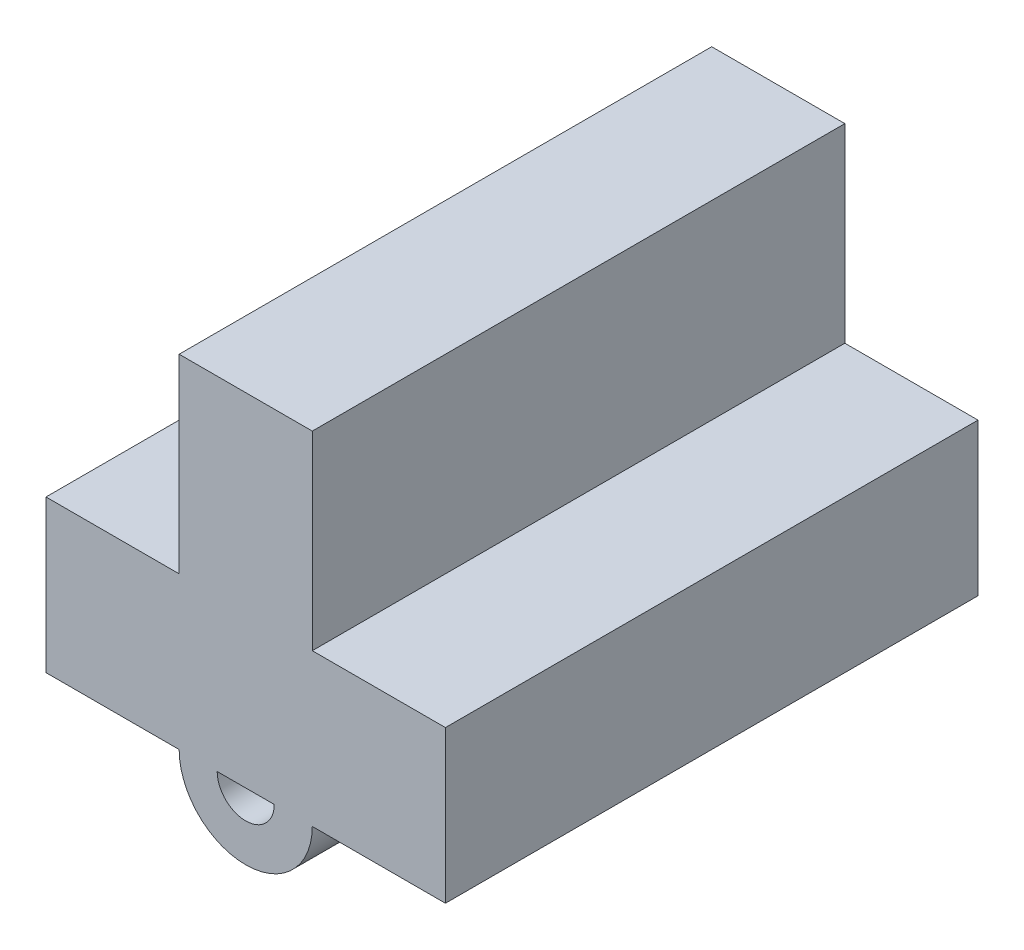
from build123d import *

# Parameters (mm, degrees)
BOSS_EXTRUDE1_DEPTH = 14
BOSS_EXTRUDE2_DEPTH = 5


with BuildPart() as part:
    # Sketch1 → Boss-Extrude1 (new body)
    with BuildSketch(Plane.XY):
        Polygon((1.75, 2), (1.75, 7), (-1.75, 7), (-1.75, 2), (-5.25, 2), (-5.25, -2), (5.25, -2), (5.25, 2), align=None)
    extrude(amount=BOSS_EXTRUDE1_DEPTH)

    # Sketch2 → Boss-Extrude2 (add)
    with BuildSketch(Plane.XY.offset(14)):
        with BuildLine():
            Line((-1.75, -2), (-0.75, -2))
            ThreePointArc((-0.75, -2), (0, -2.75), (0.75, -2))
            Line((0.75, -2), (1.75, -2))
            ThreePointArc((1.75, -2), (0, -3.75), (-1.75, -2))
        make_face()
    extrude(amount=-BOSS_EXTRUDE2_DEPTH)


solid = part.part
